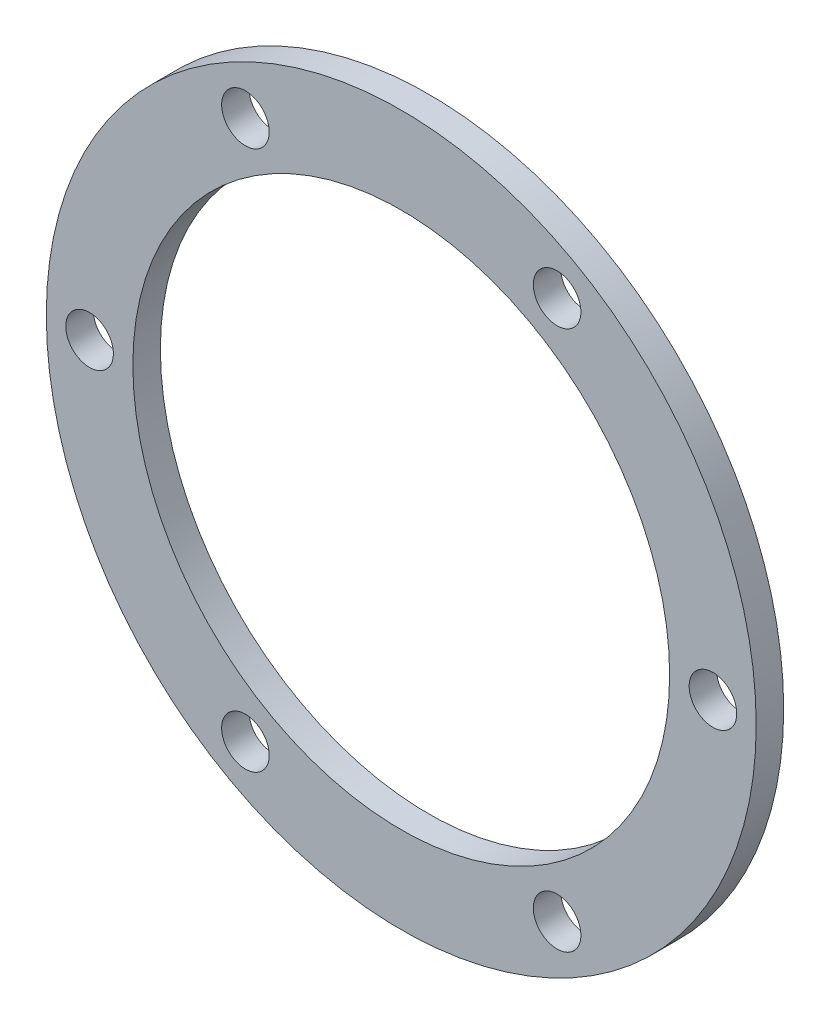
from build123d import *

# Parameters (mm, degrees)
SKETCH1_R           = 41
SKETCH1_R_2         = 31
BOSS_EXTRUDE1_DEPTH = 3.175
SKETCH2_R           = 2.75
CUT_EXTRUDE2_DEPTH  = 4.175


with BuildPart() as part:
    # Sketch1 → Boss-Extrude1 (new body)
    with BuildSketch(Plane.XY):
        Circle(SKETCH1_R)
        Circle(SKETCH1_R_2, mode=Mode.SUBTRACT)
    extrude(amount=BOSS_EXTRUDE1_DEPTH)

    # Sketch2 → Cut-Extrude2 (cut, through all)
    with BuildSketch(Plane.XY.offset(3.175)):
        with Locations((-18, 31.176914536)):
            Circle(SKETCH2_R)
        with Locations((18, 31.176914536)):
            Circle(SKETCH2_R)
        with Locations((36, 0)):
            Circle(SKETCH2_R)
        with Locations((18, -31.176914536)):
            Circle(SKETCH2_R)
        with Locations((-18, -31.176914536)):
            Circle(SKETCH2_R)
        with Locations((-36, 0)):
            Circle(SKETCH2_R)
    extrude(amount=-CUT_EXTRUDE2_DEPTH, mode=Mode.SUBTRACT)


solid = part.part
